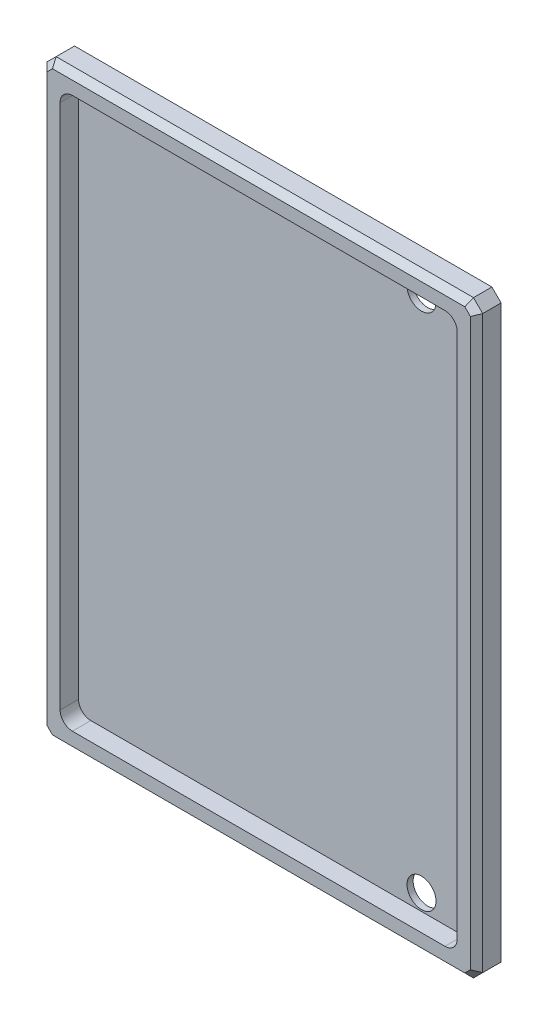
from build123d import *

# Parameters (mm, degrees)
SKETCH1_W                 = 225.425
SKETCH1_H                 = 304.8
BOSS_EXTRUDE1_DEPTH       = 12.7
CUT_EXTRUDE1_DEPTH        = 9.525
SKETCH4_R                 = 7.5
CUT_EXTRUDE3_DEPTH        = 13.7
M4X0_7_TAPPED_HOLE1_D     = 3.3
M4X0_7_TAPPED_HOLE1_DEPTH = 8
M4X0_7_TAPPED_HOLE1_TIP   = 0.991420021
CHAMFER1_SIZE             = 4.7625
CHAMFER2_SIZE             = 3.175


with BuildPart() as part:
    # Sketch1 → Boss-Extrude1 (new body)
    with BuildSketch(Plane.XY):
        Rectangle(SKETCH1_W, SKETCH1_H)
    extrude(amount=BOSS_EXTRUDE1_DEPTH)

    # Sketch2 → Cut-Extrude1 (cut)
    with BuildSketch(Plane.XY.offset(12.7)):
        with BuildLine():
            Line((96.3625, -142.4), (-96.3625, -142.4))
            ThreePointArc((-96.3625, -142.4), (-100.852628061, -140.540128061), (-102.7125, -136.05))
            Line((-102.7125, -136.05), (-102.7125, 136.05))
            ThreePointArc((-102.7125, 136.05), (-100.852628061, 140.540128061), (-96.3625, 142.4))
            Line((-96.3625, 142.4), (96.3625, 142.4))
            ThreePointArc((96.3625, 142.4), (100.852628061, 140.540128061), (102.7125, 136.05))
            Line((102.7125, 136.05), (102.7125, -136.05))
            ThreePointArc((102.7125, -136.05), (100.852628061, -140.540128061), (96.3625, -142.4))
        make_face()
    extrude(amount=-CUT_EXTRUDE1_DEPTH, mode=Mode.SUBTRACT)

    # Sketch4 → Cut-Extrude3 (cut, through all)
    with BuildSketch(Plane(origin=(0, 0, 0), x_dir=(-1, 0, 0), z_dir=(0, 0, -1))):
        with Locations((-74.7125, -134.05)):
            Circle(SKETCH4_R)
        with Locations((-74.7125, 134.05)):
            Circle(SKETCH4_R)
    extrude(amount=-CUT_EXTRUDE3_DEPTH, mode=Mode.SUBTRACT)

    # M4x0.7 Tapped Hole1
    with Locations(Plane(origin=(0, 0, 0), x_dir=(-1, 0, 0), z_dir=(0, 0, -1))):
        with Locations((107.7125, -113.6), (107.7125, 113.6)):
            Hole(M4X0_7_TAPPED_HOLE1_D / 2, depth=M4X0_7_TAPPED_HOLE1_DEPTH)
            with Locations((0, 0, -(M4X0_7_TAPPED_HOLE1_DEPTH + M4X0_7_TAPPED_HOLE1_TIP / 2))):  # 118° drill point
                Cone(0, M4X0_7_TAPPED_HOLE1_D / 2, M4X0_7_TAPPED_HOLE1_TIP, mode=Mode.SUBTRACT)

    # Chamfer1
    chamfer1_edges = [part.edges().sort_by_distance(p)[0] for p in [
        (-112.7125, 152.4, 6.35),
        (112.7125, 152.4, 6.35),
        (112.7125, -152.4, 6.35),
        (-112.7125, -152.4, 6.35),
    ]]
    chamfer(chamfer1_edges, length=CHAMFER1_SIZE)

    # Chamfer2
    chamfer2_edges = [part.edges().sort_by_distance(p)[0] for p in [
        (-112.7125, 0, 12.7),
        (0, 152.4, 12.7),
        (0, -152.4, 12.7),
        (112.7125, 0, 12.7),
        (-110.33125, -150.01875, 12.7),
        (110.33125, -150.01875, 12.7),
        (110.33125, 150.01875, 12.7),
        (-110.33125, 150.01875, 12.7),
    ]]
    chamfer(chamfer2_edges, length=CHAMFER2_SIZE)


solid = part.part
